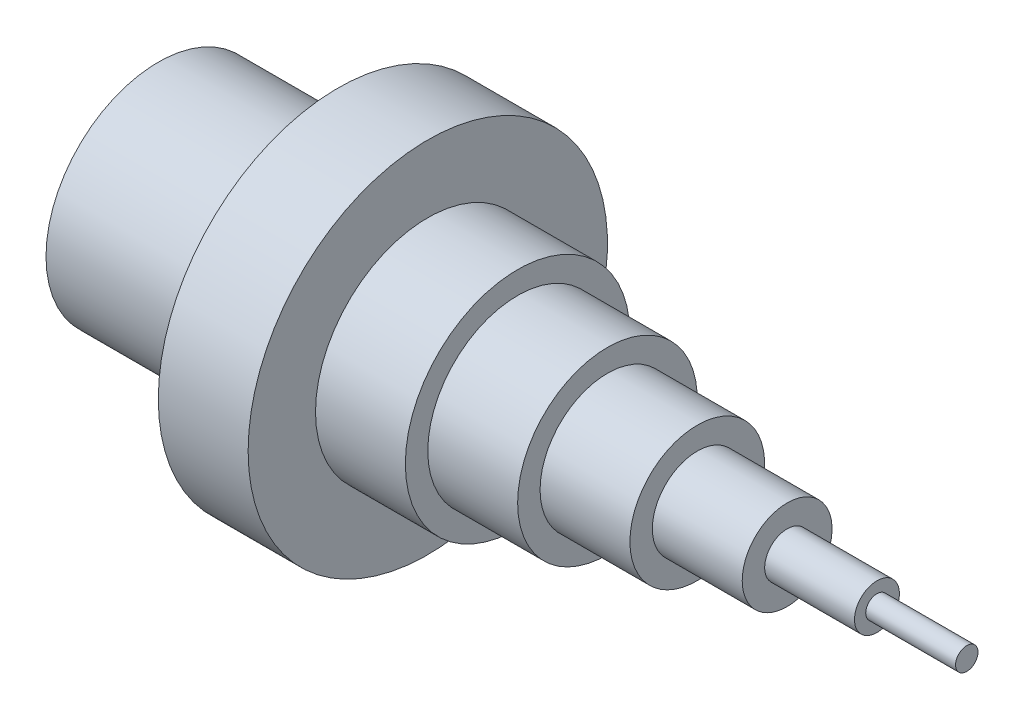
from build123d import *

# Parameters (mm, degrees)
CROQUIS2_R            = 20
CORTAR_EXTRUIR1_DEPTH = 40


with BuildPart() as part:
    # Croquis1 → Revolución1 (revolve)
    with BuildSketch(Plane.XY):
        Polygon((0, 0), (0, 2.5), (-20, 2.5), (-20, 5), (-40, 5), (-40, 10), (-60, 10), (-60, 15), (-80, 15), (-80, 20), (-100, 20), (-100, 25), (-120, 25), (-120, 40), (-140, 40), (-140, 25), (-180, 25), (-180, 0), align=None)
    revolve(axis=Axis((-180, 0, 0), (1, 0, 0)))

    # Croquis2 → Cortar-Extruir1 (cut)
    with BuildSketch(Plane.ZY.offset(180)):
        Circle(CROQUIS2_R)
    extrude(amount=-CORTAR_EXTRUIR1_DEPTH, mode=Mode.SUBTRACT)


solid = part.part
